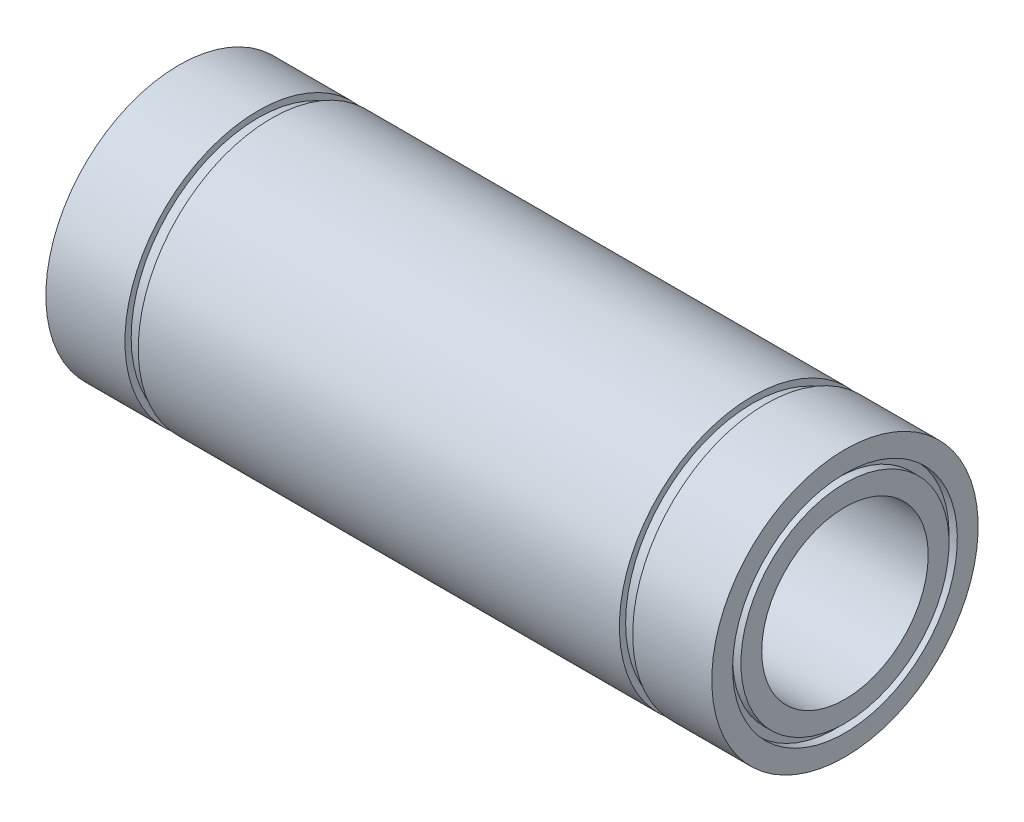
from build123d import *


with BuildPart() as part:
    # Esboço1 → Revolução1 (revolve)
    with BuildSketch(Plane.XY):
        Polygon((-40, 16), (-30.5, 16), (-30.5, 15.25), (-28.9, 15.25), (-28.9, 16), (28.9, 16), (28.9, 15.25), (30.5, 15.25), (30.5, 16), (40, 16), (40, 13.5), (39, 13.5), (39, 12.5), (40, 12.5), (40, 10), (-40, 10), (-40, 12.5), (-39, 12.5), (-39, 13.5), (-40, 13.5), align=None)
    revolve(axis=Axis((0, 0, 0), (-1, 0, 0)))


solid = part.part
